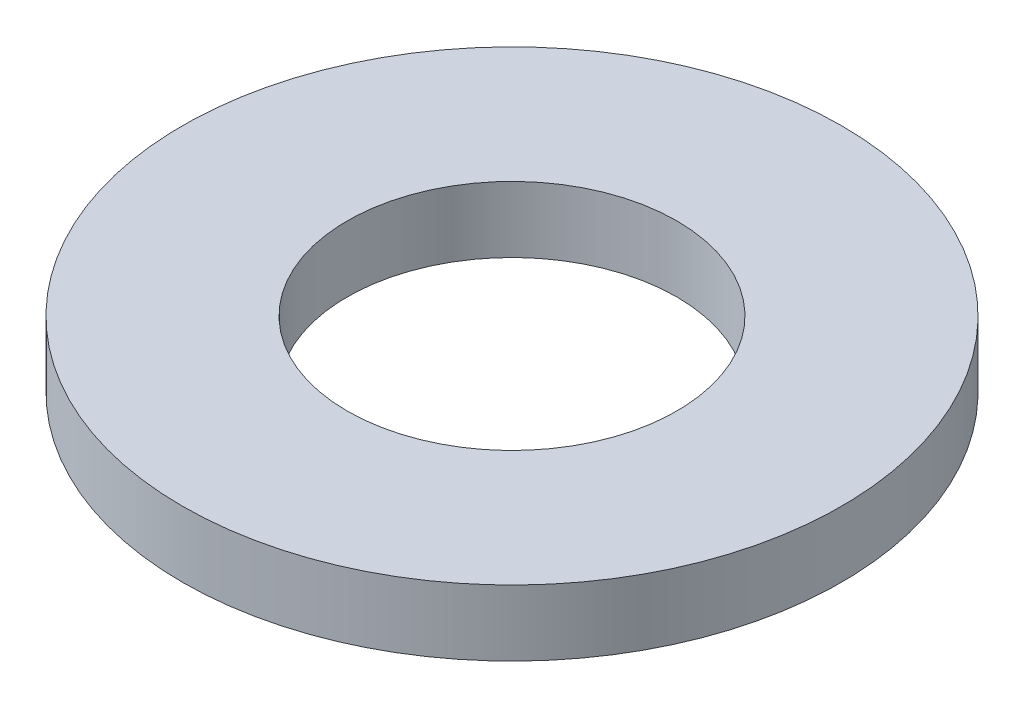
from build123d import *

# Parameters (mm, degrees)
SKETCH1_R           = 5
SKETCH1_R_2         = 2.5
BOSS_EXTRUDE1_DEPTH = 1


with BuildPart() as part:
    # Sketch1 → Boss-Extrude1 (new body)
    with BuildSketch(Plane(origin=(0, 0, 0), x_dir=(1, 0, 0), z_dir=(0, 1, 0))):
        Circle(SKETCH1_R)
        Circle(SKETCH1_R_2, mode=Mode.SUBTRACT)
    extrude(amount=BOSS_EXTRUDE1_DEPTH)


solid = part.part
